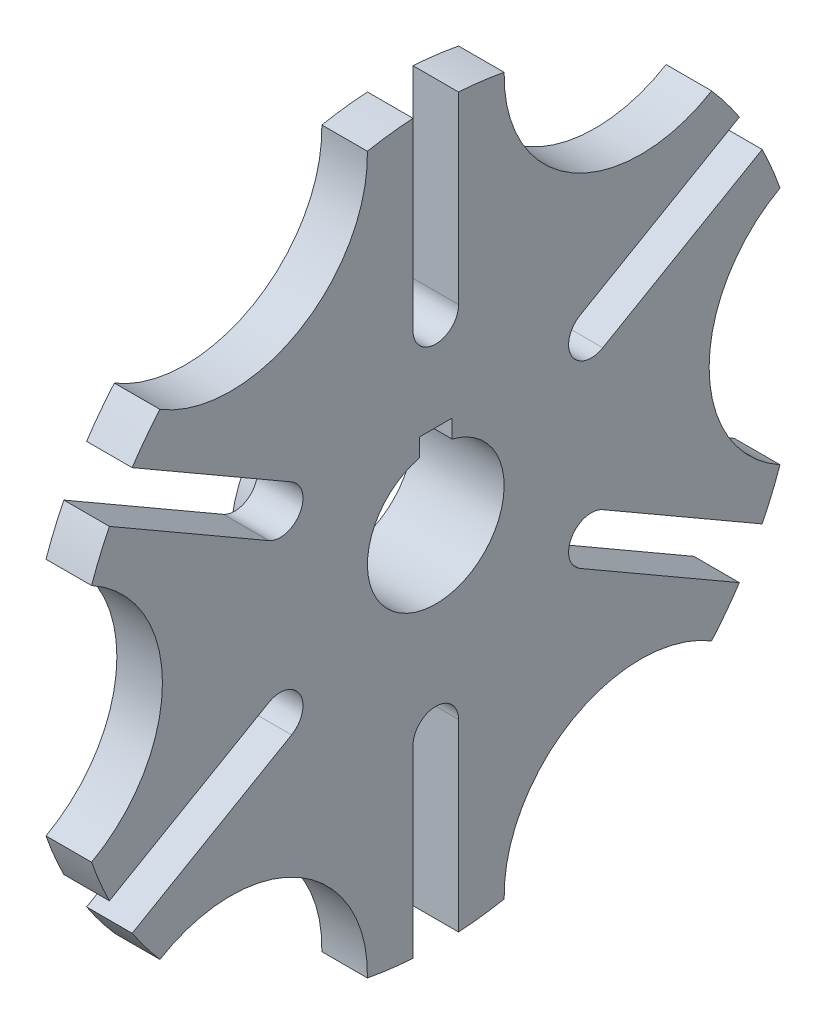
from build123d import *

# Parameters (mm, degrees)
SKETCH2_R          = 19.05
CUT_EXTRUDE1_DEPTH = 26.4
SKETCH3_R          = 38.1
CUT_EXTRUDE2_DEPTH = 13.7
CUT_EXTRUDE5_DEPTH = 13.7
SKETCH6_W          = 9.144
SKETCH6_H          = 5.08
CUT_EXTRUDE6_DEPTH = 26.4


with BuildPart() as part:
    # Sketch1 → Revolve1 (revolve)
    with BuildSketch(Plane.XY):
        with BuildLine():
            Line((0, 0), (0, 31.75))
            Line((0, 31.75), (6.35, 31.75))
            ThreePointArc((6.35, 31.75), (10.840128061, 33.609871939), (12.7, 38.1))
            Line((12.7, 38.1), (12.7, 101.6))
            Line((12.7, 101.6), (25.4, 101.6))
            Line((25.4, 101.6), (25.4, 0))
            Line((25.4, 0), (0, 0))
        make_face()
    revolve(axis=Axis((25.4, 0, 0), (-1, 0, 0)))

    # Sketch2 → Cut-Extrude1 (cut, through all)
    with BuildSketch(Plane.ZY):
        Circle(SKETCH2_R)
    extrude(amount=-CUT_EXTRUDE1_DEPTH, mode=Mode.SUBTRACT)

    # Sketch3 → Cut-Extrude2 (cut, through all)
    with BuildSketch(Plane.ZY.offset(-12.7)):
        with Locations((114.3, 0)):
            Circle(SKETCH3_R)
        with Locations((57.15, -98.986703653)):
            Circle(SKETCH3_R)
        with Locations((-57.15, -98.986703653)):
            Circle(SKETCH3_R)
        with Locations((-114.3, 0)):
            Circle(SKETCH3_R)
        with Locations((-57.15, 98.986703653)):
            Circle(SKETCH3_R)
        with Locations((57.15, 98.986703653)):
            Circle(SKETCH3_R)
    extrude(amount=-CUT_EXTRUDE2_DEPTH, mode=Mode.SUBTRACT)

    # Sketch5 → Cut-Extrude5 (cut, through all)
    with BuildSketch(Plane.ZY.offset(-12.7)):
        with BuildLine():
            Line((113.723029824, 58.325673463), (46.547661143, 19.541956272))
            ThreePointArc((46.547661143, 19.541956272), (37.873399829, 21.866217586), (40.197661143, 30.5404789))
            Line((40.197661143, 30.5404789), (107.373029824, 69.324196091))
            Line((107.373029824, 69.324196091), (113.723029824, 58.325673463))
        make_face()
        with BuildLine():
            Line((-6.35, 127.649869555), (6.35, 127.649869555))
            Line((6.35, 127.649869555), (6.35, 50.082435173))
            ThreePointArc((6.35, 50.082435173), (0, 43.732435173), (-6.35, 50.082435173))
            Line((-6.35, 50.082435173), (-6.35, 127.649869555))
        make_face()
        with BuildLine():
            Line((107.373029824, -69.324196091), (40.197661143, -30.5404789))
            ThreePointArc((40.197661143, -30.5404789), (37.873399829, -21.866217586), (46.547661143, -19.541956272))
            Line((46.547661143, -19.541956272), (113.723029824, -58.325673463))
            Line((113.723029824, -58.325673463), (107.373029824, -69.324196091))
        make_face()
        with BuildLine():
            Line((-6.35, -127.649869555), (-6.35, -50.082435173))
            ThreePointArc((-6.35, -50.082435173), (0, -43.732435173), (6.35, -50.082435173))
            Line((6.35, -50.082435173), (6.35, -127.649869555))
            Line((6.35, -127.649869555), (-6.35, -127.649869555))
        make_face()
        with BuildLine():
            Line((-113.723029824, -58.325673463), (-46.547661143, -19.541956272))
            ThreePointArc((-46.547661143, -19.541956272), (-37.873399829, -21.866217586), (-40.197661143, -30.5404789))
            Line((-40.197661143, -30.5404789), (-107.373029824, -69.324196091))
            Line((-107.373029824, -69.324196091), (-113.723029824, -58.325673463))
        make_face()
        with BuildLine():
            Line((-107.373029824, 69.324196091), (-40.197661143, 30.5404789))
            ThreePointArc((-40.197661143, 30.5404789), (-37.873399829, 21.866217586), (-46.547661143, 19.541956272))
            Line((-46.547661143, 19.541956272), (-113.723029824, 58.325673463))
            Line((-113.723029824, 58.325673463), (-107.373029824, 69.324196091))
        make_face()
    extrude(amount=-CUT_EXTRUDE5_DEPTH, mode=Mode.SUBTRACT)

    # Sketch6 → Cut-Extrude6 (cut, through all)
    with BuildSketch(Plane.ZY):
        with Locations((0, 21.033223516)):
            Rectangle(SKETCH6_W, SKETCH6_H)
    extrude(amount=-CUT_EXTRUDE6_DEPTH, mode=Mode.SUBTRACT)


solid = part.part
